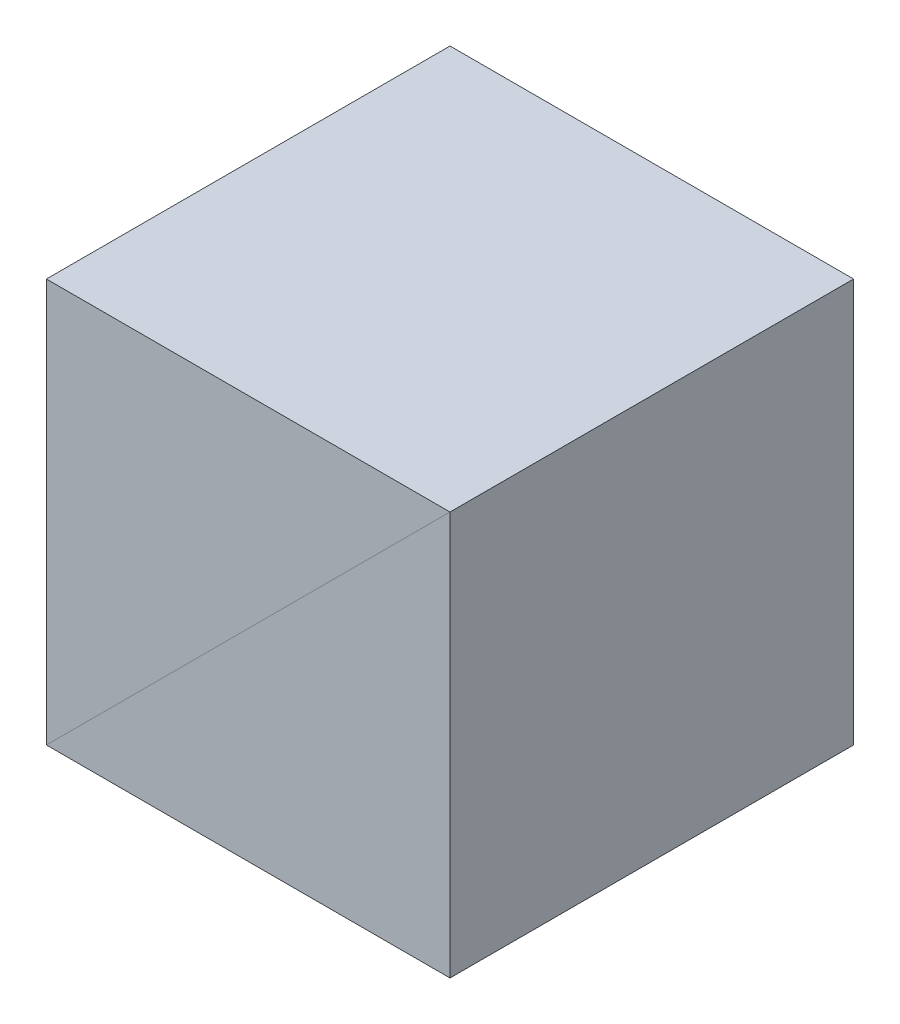
from build123d import *

# Parameters (mm, degrees)
EXTRUDE_1_DEPTH = 6.35


with BuildPart() as part:
    # 草图1 → 凸台-拉伸1 (new body, symmetric)
    with BuildSketch(Plane.XY):
        Polygon((-6.35, -6.35), (6.35, -6.35), (6.35, 6.35), align=None)
    extrude(amount=EXTRUDE_1_DEPTH, both=True)


with BuildPart() as body_2:
    # 镜向2: mirrored copy
    add(part.part.mirror(Plane(origin=(6.35, 6.35, 6.35), x_dir=(0, 0, 1), z_dir=(0.707106781, -0.707106781, 0))))


solid = Compound([part.part, body_2.part])
